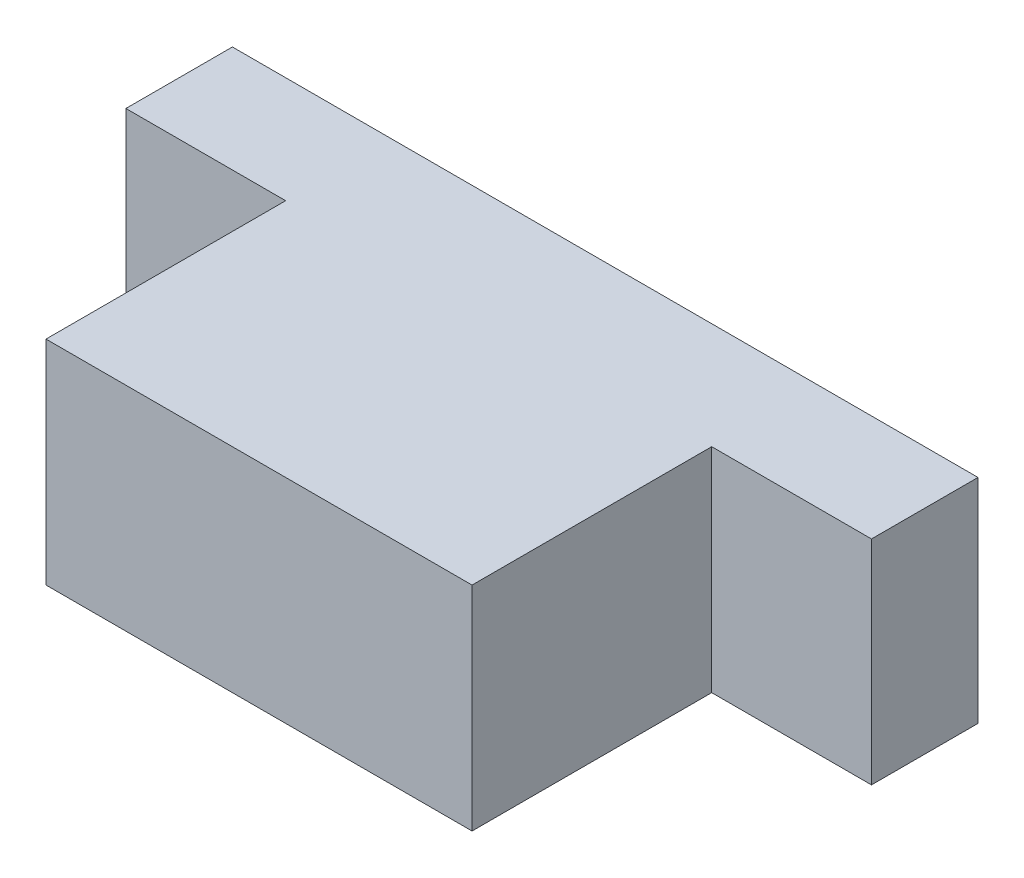
from build123d import *

# Parameters (mm, degrees)
SKETCH1_W           = 40
SKETCH1_H           = 20
BOSS_EXTRUDE1_DEPTH = 22.5
SKETCH2_W           = 70
SKETCH2_H           = 20
BOSS_EXTRUDE2_DEPTH = 10


with BuildPart() as part:
    # Sketch1 → Boss-Extrude1 (new body)
    with BuildSketch(Plane.XY):
        Rectangle(SKETCH1_W, SKETCH1_H)
    extrude(amount=BOSS_EXTRUDE1_DEPTH)

    # Sketch2 → Boss-Extrude2 (add)
    with BuildSketch(Plane(origin=(0, 0, 0), x_dir=(-1, 0, 0), z_dir=(0, 0, -1))):
        Rectangle(SKETCH2_W, SKETCH2_H)
    extrude(amount=BOSS_EXTRUDE2_DEPTH)


solid = part.part
